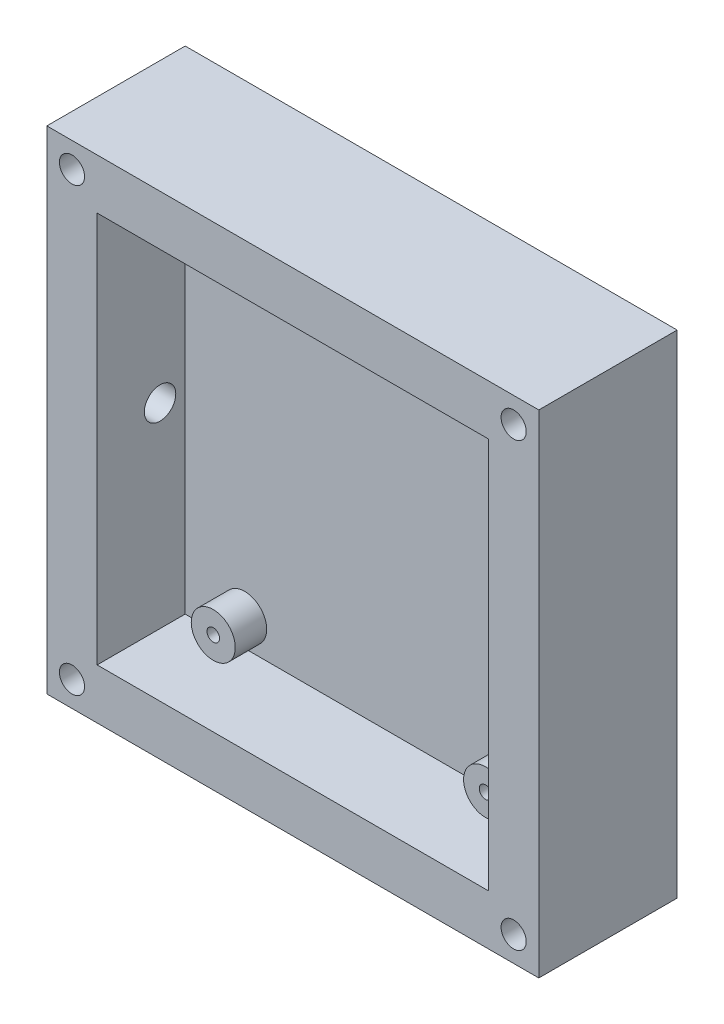
from build123d import *

# Parameters (mm, degrees)
ESQUISSE1_W             = 78.22
ESQUISSE1_H             = 78.22
BOSS_EXTRU_1_DEPTH      = 22
COQUE1_T                = -8
ESQUISSE2_R             = 2
ENL_V_MAT_EXTRU_1_DEPTH = 14
ESQUISSE3_R             = 3.5
BOSS_EXTRU_2_DEPTH      = 5
ESQUISSE3_4_R           = 1
ENL_V_MAT_EXTRU_3_DEPTH = 5
ESQUISSE6_R             = 2.5
ENL_V_MAT_EXTRU_4_DEPTH = 12


with BuildPart() as part:
    # Esquisse1 → Boss.-Extru.1 (new body)
    with BuildSketch(Plane.XY):
        Rectangle(ESQUISSE1_W, ESQUISSE1_H)
    extrude(amount=BOSS_EXTRU_1_DEPTH)

    # Coque1
    coque1_openings = [part.faces().sort_by_distance(p)[0] for p in [
        (0, 0, 22),
    ]]
    offset(amount=COQUE1_T, openings=coque1_openings, kind=Kind.INTERSECTION)

    # Esquisse2 → Enl_v. mat.-Extru.1 (cut)
    with BuildSketch(Plane.XY.offset(22)):
        with Locations((-35.11, 35.11)):
            Circle(ESQUISSE2_R)
        with Locations((35.11, -35.11)):
            Circle(ESQUISSE2_R)
        with Locations((35.11, 35.11)):
            Circle(ESQUISSE2_R)
        with Locations((-35.11, -35.11)):
            Circle(ESQUISSE2_R)
    extrude(amount=-ENL_V_MAT_EXTRU_1_DEPTH, mode=Mode.SUBTRACT)

    # Esquisse3 → Boss.-Extru.2 (add)
    with BuildSketch(Plane.XY.offset(8)):
        with Locations((-21.65, 26.75)):
            Circle(ESQUISSE3_R)
        with Locations((-21.65, -26.75)):
            Circle(ESQUISSE3_R)
        with Locations((21.65, -26.75)):
            Circle(ESQUISSE3_R)
        with Locations((21.65, 26.75)):
            Circle(ESQUISSE3_R)
    extrude(amount=BOSS_EXTRU_2_DEPTH)

    # Esquisse3_4 → Enl_v. mat.-Extru.3 (cut)
    with BuildSketch(Plane.XY.offset(8)):
        with Locations((-21.65, 26.75)):
            Circle(ESQUISSE3_4_R)
        with Locations((-21.65, -26.75)):
            Circle(ESQUISSE3_4_R)
        with Locations((21.65, -26.75)):
            Circle(ESQUISSE3_4_R)
        with Locations((21.65, 26.75)):
            Circle(ESQUISSE3_4_R)
    extrude(amount=ENL_V_MAT_EXTRU_3_DEPTH, mode=Mode.SUBTRACT)

    # Esquisse6 → Enl_v. mat.-Extru.4 (cut)
    with BuildSketch(Plane.ZY.offset(39.11)):
        with Locations((12, -0.040287358)):
            Circle(ESQUISSE6_R)
    extrude(amount=-ENL_V_MAT_EXTRU_4_DEPTH, mode=Mode.SUBTRACT)


solid = part.part
